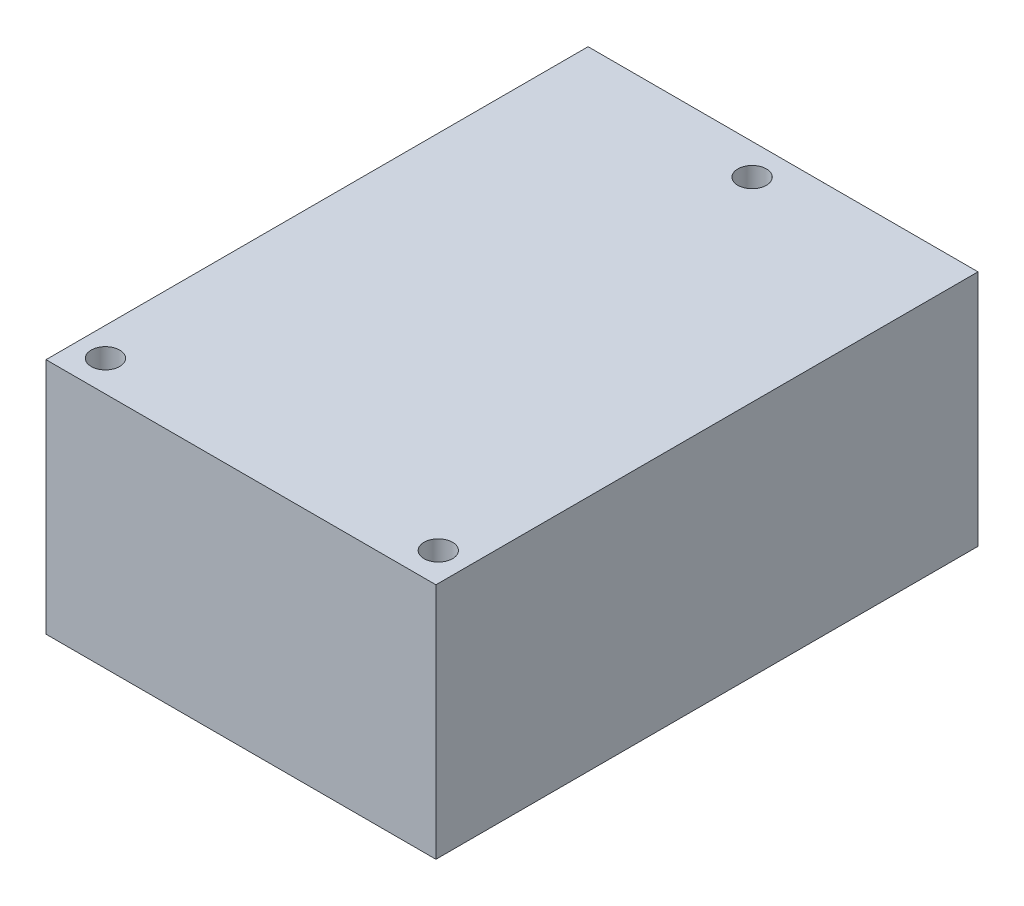
from build123d import *

# Parameters (mm, degrees)
SKETCH_1_W          = 41
SKETCH_1_H          = 57
EXTRUDE_1_DEPTH     = 25
SKETCH_2_R          = 1.5
CUT_EXTRUDE_1_DEPTH = 26


with BuildPart() as part:
    # 草图1 → 凸台-拉伸1 (new body)
    with BuildSketch(Plane(origin=(0, 0, 0), x_dir=(1, 0, 0), z_dir=(0, 1, 0))):
        Rectangle(SKETCH_1_W, SKETCH_1_H)
    extrude(amount=EXTRUDE_1_DEPTH)

    # 草图2 → 切除-拉伸1 (cut, through all)
    with BuildSketch(Plane(origin=(0, 25, 0), x_dir=(1, 0, 0), z_dir=(0, 1, 0))):
        with Locations((0, 25.25)):
            Circle(SKETCH_2_R)
        with Locations((-17.5, -25.25)):
            Circle(SKETCH_2_R)
        with Locations((17.5, -25.25)):
            Circle(SKETCH_2_R)
    extrude(amount=-CUT_EXTRUDE_1_DEPTH, mode=Mode.SUBTRACT)


solid = part.part
